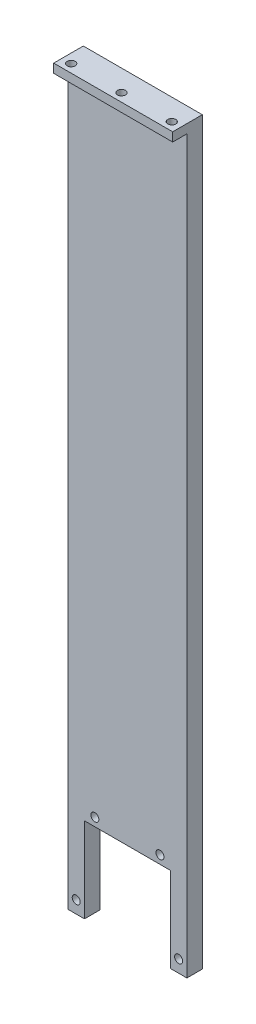
from build123d import *

# Parameters (mm, degrees)
SKETCH1_W           = 40.2
SKETCH1_H           = 250
BOSS_EXTRUDE1_DEPTH = 10
SKETCH4_W           = 40.2
SKETCH4_H           = 247
CUT_EXTRUDE1_DEPTH  = 4.8
SKETCH3_W           = 29
SKETCH3_H           = 28.7
CUT_EXTRUDE2_DEPTH  = 11
SKETCH2_R           = 1.35
CUT_EXTRUDE3_DEPTH  = 11
SKETCH6_R           = 1.35
CUT_EXTRUDE4_DEPTH  = 251


with BuildPart() as part:
    # Sketch1 → Boss-Extrude1 (new body)
    with BuildSketch(Plane.XY):
        Rectangle(SKETCH1_W, SKETCH1_H)
    extrude(amount=BOSS_EXTRUDE1_DEPTH)

    # Sketch4 → Cut-Extrude1 (cut)
    with BuildSketch(Plane.XY.offset(10)):
        with Locations((0, -1.5)):
            Rectangle(SKETCH4_W, SKETCH4_H)
    extrude(amount=-CUT_EXTRUDE1_DEPTH, mode=Mode.SUBTRACT)

    # Sketch3 → Cut-Extrude2 (cut, through all)
    with BuildSketch(Plane.XY.offset(10)):
        with Locations((0, -110.65)):
            Rectangle(SKETCH3_W, SKETCH3_H)
    extrude(amount=-CUT_EXTRUDE2_DEPTH, mode=Mode.SUBTRACT)

    # Sketch2 → Cut-Extrude3 (cut, through all)
    with BuildSketch(Plane.XY.offset(10)):
        with Locations((17.3, -120.8)):
            Circle(SKETCH2_R)
        with Locations((11, -93.5)):
            Circle(SKETCH2_R)
        with Locations((-17.3, -120.8)):
            Circle(SKETCH2_R)
        with Locations((-11, -93.5)):
            Circle(SKETCH2_R)
    extrude(amount=-CUT_EXTRUDE3_DEPTH, mode=Mode.SUBTRACT)

    # Sketch6 → Cut-Extrude4 (cut, through all)
    with BuildSketch(Plane(origin=(0, 125, 0), x_dir=(-1, 0, 0), z_dir=(0, 1, 0))):
        with Locations((-17, 7.2)):
            Circle(SKETCH6_R)
        with Locations((17, 7.2)):
            Circle(SKETCH6_R)
        with Locations((0, 7.2)):
            Circle(SKETCH6_R)
    extrude(amount=-CUT_EXTRUDE4_DEPTH, mode=Mode.SUBTRACT)


solid = part.part
